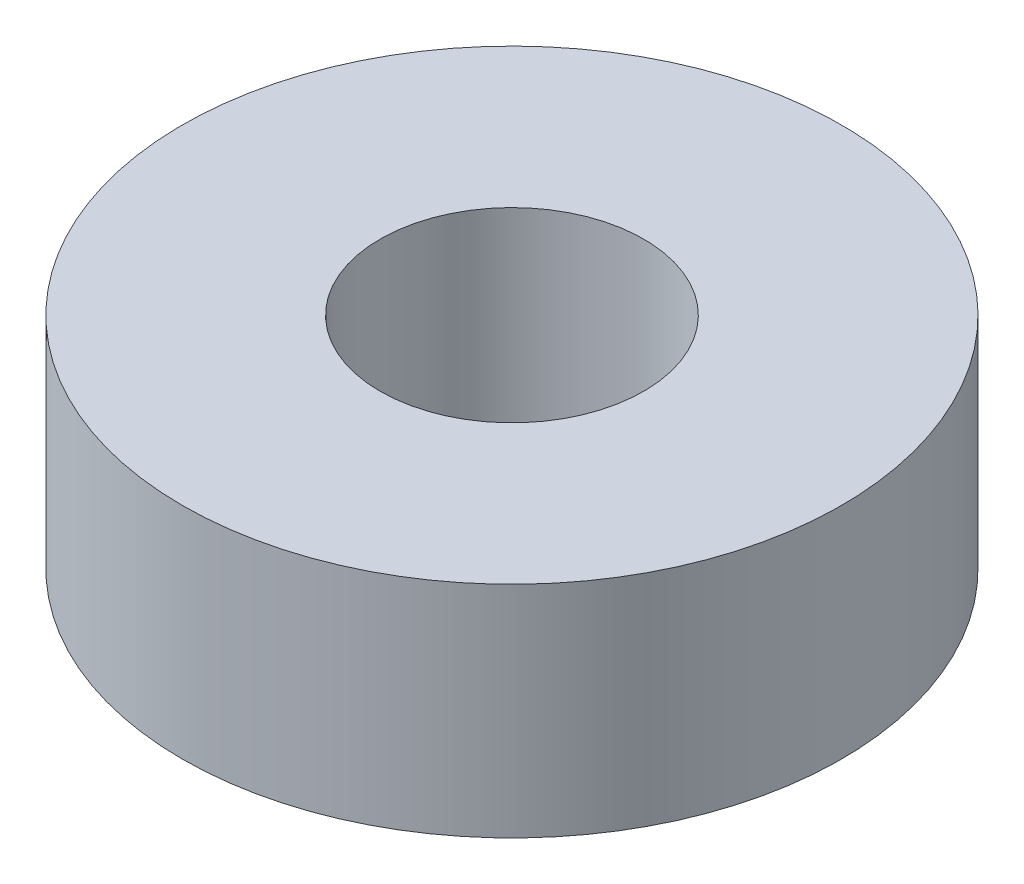
from build123d import *

# Parameters (mm, degrees)
SKETCH1_R           = 7.5
BOSS_EXTRUDE1_DEPTH = 5
SKETCH1_3_R         = 3
CUT_EXTRUDE1_DEPTH  = 5


with BuildPart() as part:
    # Sketch1 → Boss-Extrude1 (new body)
    with BuildSketch(Plane(origin=(0, 0, 0), x_dir=(1, 0, 0), z_dir=(0, 1, 0))):
        Circle(SKETCH1_R)
    extrude(amount=BOSS_EXTRUDE1_DEPTH)

    # Sketch1_3 → Cut-Extrude1 (cut)
    with BuildSketch(Plane(origin=(0, 0, 0), x_dir=(1, 0, 0), z_dir=(0, 1, 0))):
        Circle(SKETCH1_3_R)
    extrude(amount=CUT_EXTRUDE1_DEPTH, mode=Mode.SUBTRACT)


solid = part.part
